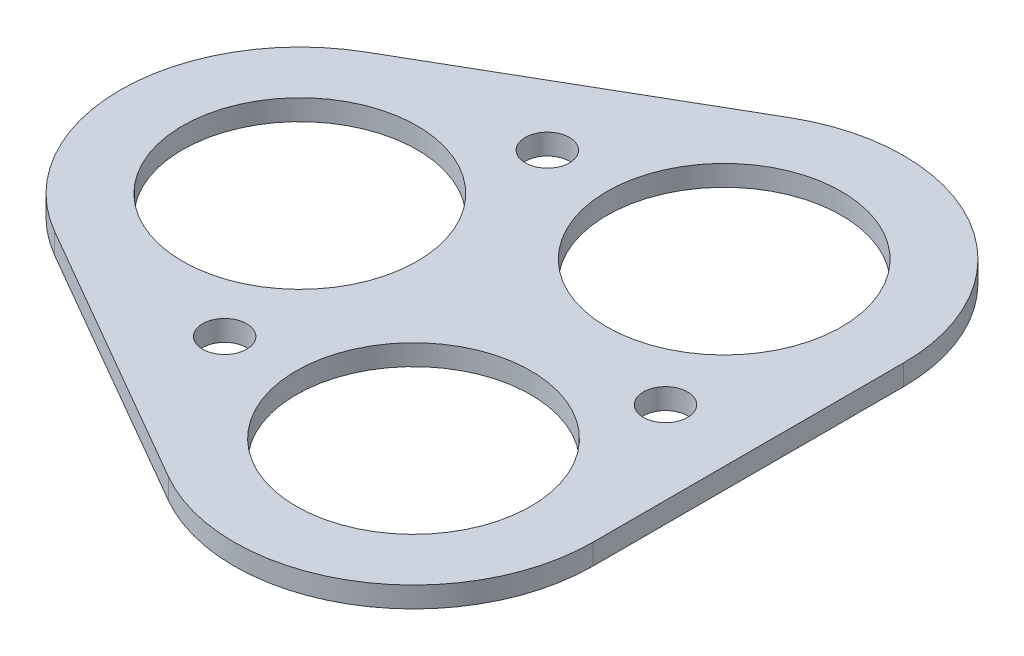
from build123d import *

# Parameters (mm, degrees)
SKETCH1_R           = 8.5
SKETCH1_R_2         = 1.6
SKETCH1_R_3         = 1.599999998
BOSS_EXTRUDE1_DEPTH = 1.5


with BuildPart() as part:
    # Sketch1 → Boss-Extrude1 (new body)
    with BuildSketch(Plane(origin=(0, 0, 0), x_dir=(1, 0, 0), z_dir=(0, 1, 0))):
        with BuildLine():
            Line((-15.804326324, -11.258330249), (3.681245261, -22.508330249))
            ThreePointArc((3.681245261, -22.508330249), (16.681245261, -22.508330249), (23.181245261, -11.25))
            Line((23.181245261, -11.25), (23.181245261, 11.25))
            ThreePointArc((23.181245261, 11.25), (16.681245261, 22.508330249), (3.681245261, 22.508330249))
            Line((3.681245261, 22.508330249), (-15.804326324, 11.258330249))
            ThreePointArc((-15.804326324, 11.258330249), (-22.304326324, 0), (-15.804326324, -11.258330249))
        make_face()
        with Locations((-9.304326324, 0)):
            Circle(SKETCH1_R, mode=Mode.SUBTRACT)
        with Locations((-3.06154027, 11.687177858)):
            Circle(SKETCH1_R_2, mode=Mode.SUBTRACT)
        with Locations((17.181245264, 0)):
            Circle(SKETCH1_R_3, mode=Mode.SUBTRACT)
        with Locations((10.181245261, -11.25)):
            Circle(SKETCH1_R, mode=Mode.SUBTRACT)
        with Locations((10.181245261, 11.25)):
            Circle(SKETCH1_R, mode=Mode.SUBTRACT)
        with Locations((-3.06154027, -11.687177373)):
            Circle(SKETCH1_R_2, mode=Mode.SUBTRACT)
    extrude(amount=BOSS_EXTRUDE1_DEPTH)


solid = part.part
